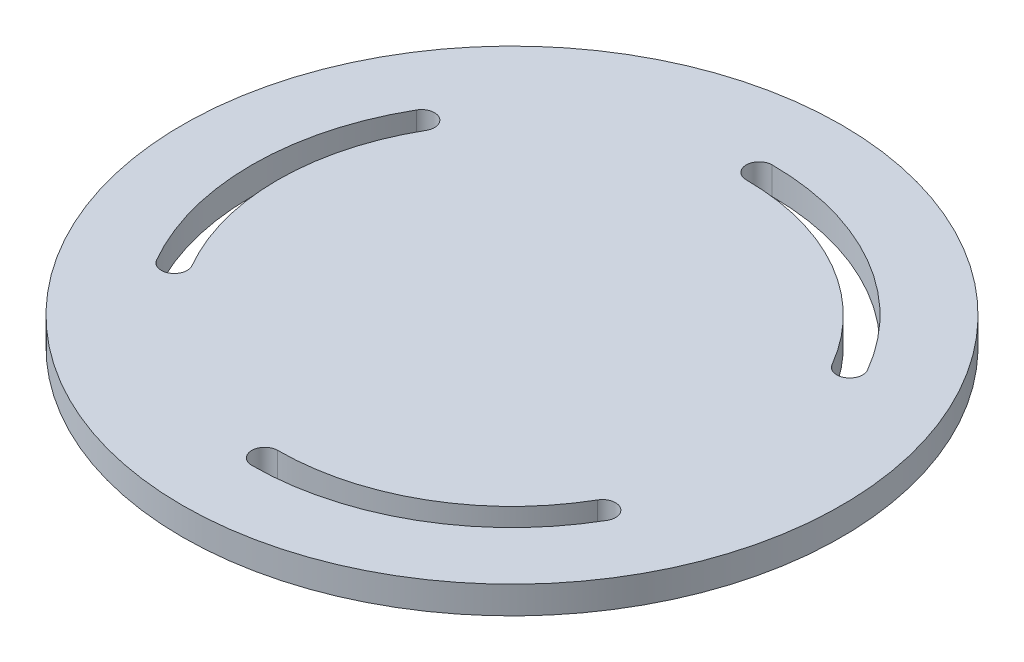
from build123d import *

# Parameters (mm, degrees)
SKETCH2_R           = 76.1746
BOSS_EXTRUDE1_DEPTH = 6.35


with BuildPart() as part:
    # Sketch2 → Boss-Extrude1 (new body)
    with BuildSketch(Plane(origin=(0, 0, 0), x_dir=(1, 0, 0), z_dir=(0, 1, 0))):
        Circle(SKETCH2_R)
        with BuildLine():
            ThreePointArc((52.091428011, 30.074999984), (30.074999985, 52.091428011), (0, 60.149999969))
            ThreePointArc((0, 60.149999969), (-2.999999969, 57.15), (0, 54.150000031))
            ThreePointArc((0, 54.150000031), (27.075000016, 46.895275642), (46.895275642, 27.075000015))
            ThreePointArc((46.895275642, 27.075000015), (50.993351811, 25.976923815), (52.091428011, 30.074999984))
        make_face(mode=Mode.SUBTRACT)
        with BuildLine():
            ThreePointArc((0, -54.150000031), (27.075000016, -46.895275642), (46.895275642, -27.075000015))
            ThreePointArc((46.895275642, -27.075000015), (50.993351811, -25.976923815), (52.091428011, -30.074999985))
            ThreePointArc((52.091428011, -30.074999985), (30.074999984, -52.091428011), (0, -60.149999969))
            ThreePointArc((0, -60.149999969), (-2.999999969, -57.15), (0, -54.150000031))
        make_face(mode=Mode.SUBTRACT)
        with BuildLine():
            ThreePointArc((-46.895275642, 27.075000015), (-54.150000031, 0), (-46.895275642, -27.075000016))
            ThreePointArc((-46.895275642, -27.075000016), (-47.993351842, -31.173076185), (-52.091428011, -30.074999985))
            ThreePointArc((-52.091428011, -30.074999985), (-60.149999969, 0), (-52.091428011, 30.074999984))
            ThreePointArc((-52.091428011, 30.074999984), (-47.993351842, 31.173076185), (-46.895275642, 27.075000015))
        make_face(mode=Mode.SUBTRACT)
    extrude(amount=-BOSS_EXTRUDE1_DEPTH)


solid = part.part
